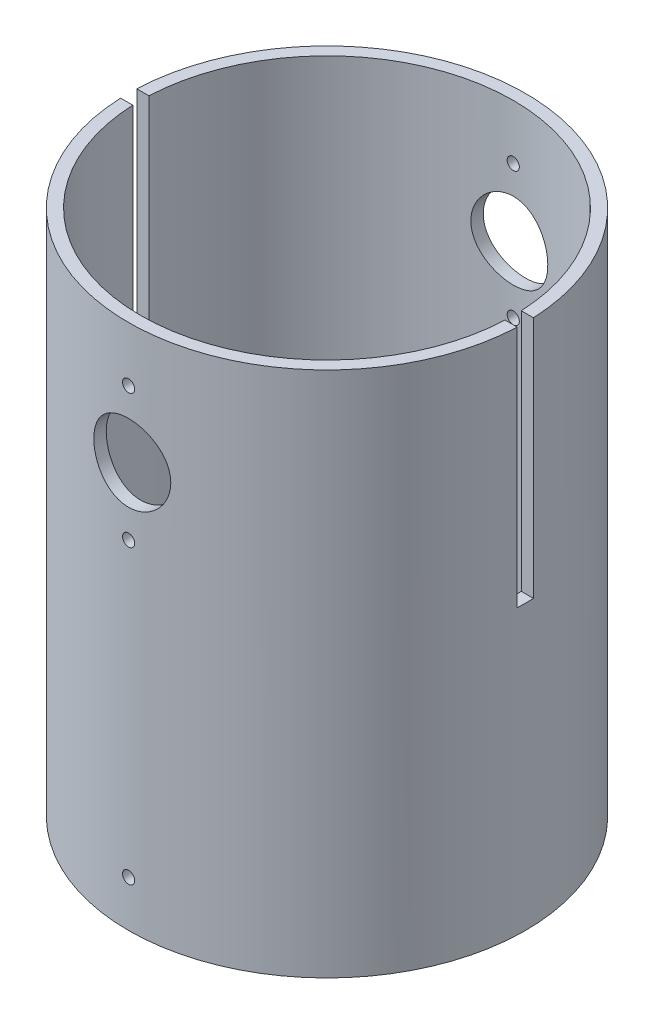
from build123d import *

# Parameters (mm, degrees)
SKETCH1_R               = 49
SKETCH1_R_2             = 46
BOSS_EXTRUDE1_DEPTH     = 130
CUT_EXTRUDE1_DEPTH      = 148.315986912
CUT_EXTRUDE1_DEPTH_BACK = 148.315986912
SKETCH2_R               = 1.5
CUT_EXTRUDE2_DEPTH      = 148.31598707
CUT_EXTRUDE2_DEPTH_BACK = 148.31598707
SKETCH3_R               = 9.5
CUT_EXTRUDE3_DEPTH      = 148.31598707
CUT_EXTRUDE3_DEPTH_BACK = 148.31598707
SKETCH4_R               = 1.5
CUT_EXTRUDE4_DEPTH      = 70
CUT_EXTRUDE4_DEPTH_BACK = 70


with BuildPart() as part:
    # Sketch1 → Boss-Extrude1 (new body)
    with BuildSketch(Plane(origin=(0, 0, 0), x_dir=(1, 0, 0), z_dir=(0, 1, 0))):
        Circle(SKETCH1_R)
        Circle(SKETCH1_R_2, mode=Mode.SUBTRACT)
    extrude(amount=BOSS_EXTRUDE1_DEPTH)

    # Sketch2 → Cut-Extrude1 (cut, two sides: drawn at the far end of the back side and taken through both)
    with BuildSketch(Plane.XY.offset(-CUT_EXTRUDE1_DEPTH_BACK)):
        with Locations((0, 11.4)):
            Circle(SKETCH2_R)
    extrude(amount=CUT_EXTRUDE1_DEPTH + CUT_EXTRUDE1_DEPTH_BACK, mode=Mode.SUBTRACT)

    # Sketch3 → Cut-Extrude2 (cut, two sides: drawn at the far end of the back side and taken through both)
    with BuildSketch(Plane.XY.offset(-CUT_EXTRUDE2_DEPTH_BACK)):
        with Locations((0, 100)):
            Circle(SKETCH3_R)
    extrude(amount=CUT_EXTRUDE2_DEPTH + CUT_EXTRUDE2_DEPTH_BACK, mode=Mode.SUBTRACT)

    # Sketch4 → Cut-Extrude3 (cut, two sides: drawn at the far end of the back side and taken through both)
    with BuildSketch(Plane.XY.offset(-CUT_EXTRUDE3_DEPTH_BACK)):
        with Locations((0, 83.5)):
            Circle(SKETCH4_R)
        with Locations((0, 116.5)):
            Circle(SKETCH4_R)
    extrude(amount=CUT_EXTRUDE3_DEPTH + CUT_EXTRUDE3_DEPTH_BACK, mode=Mode.SUBTRACT)

    # Sketch5 → Cut-Extrude4 (cut, two sides: drawn at the far end of the back side and taken through both)
    with BuildSketch(Plane(origin=(0, 0, 0), x_dir=(0, 0, -1), z_dir=(1, 0, 0)).offset(-CUT_EXTRUDE4_DEPTH_BACK)):
        Polygon((0, 70), (2, 70), (2, 130), (-2, 130), (-2, 70), align=None)
    extrude(amount=CUT_EXTRUDE4_DEPTH + CUT_EXTRUDE4_DEPTH_BACK, mode=Mode.SUBTRACT)


solid = part.part
